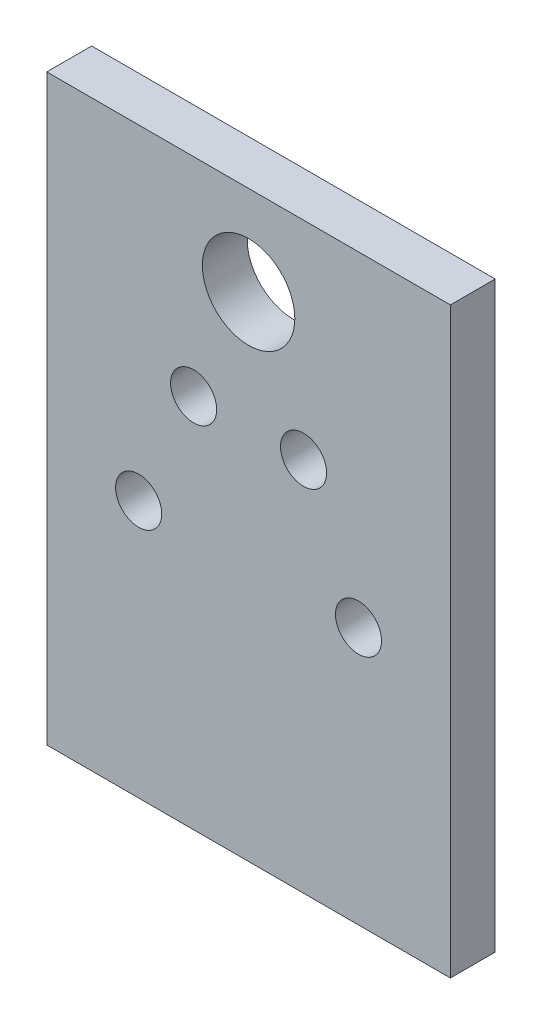
from build123d import *

# Parameters (mm, degrees)
SKETCH1_R           = 6.54812
SKETCH1_R_2         = 3.2639
BOSS_EXTRUDE1_DEPTH = 6.35


with BuildPart() as part:
    # Sketch1 → Boss-Extrude1 (new body)
    with BuildSketch(Plane.XY):
        Polygon((-28.575, 12.7), (-28.575, -12.7), (28.575, -12.7), (28.575, 12.7), (28.575, 57.15), (28.575, 69.85), (-28.575, 69.85), (-28.575, 57.15), align=None)
        with Locations((0, 57.15)):
            Circle(SKETCH1_R, mode=Mode.SUBTRACT)
        with Locations((-7.78251529, 40.460342102)):
            Circle(SKETCH1_R_2, mode=Mode.SUBTRACT)
        with Locations((-15.56503058, 23.770684203)):
            Circle(SKETCH1_R_2, mode=Mode.SUBTRACT)
        with Locations((7.78251529, 40.460342102)):
            Circle(SKETCH1_R_2, mode=Mode.SUBTRACT)
        with Locations((15.56503058, 23.770684203)):
            Circle(SKETCH1_R_2, mode=Mode.SUBTRACT)
    extrude(amount=BOSS_EXTRUDE1_DEPTH)


solid = part.part
